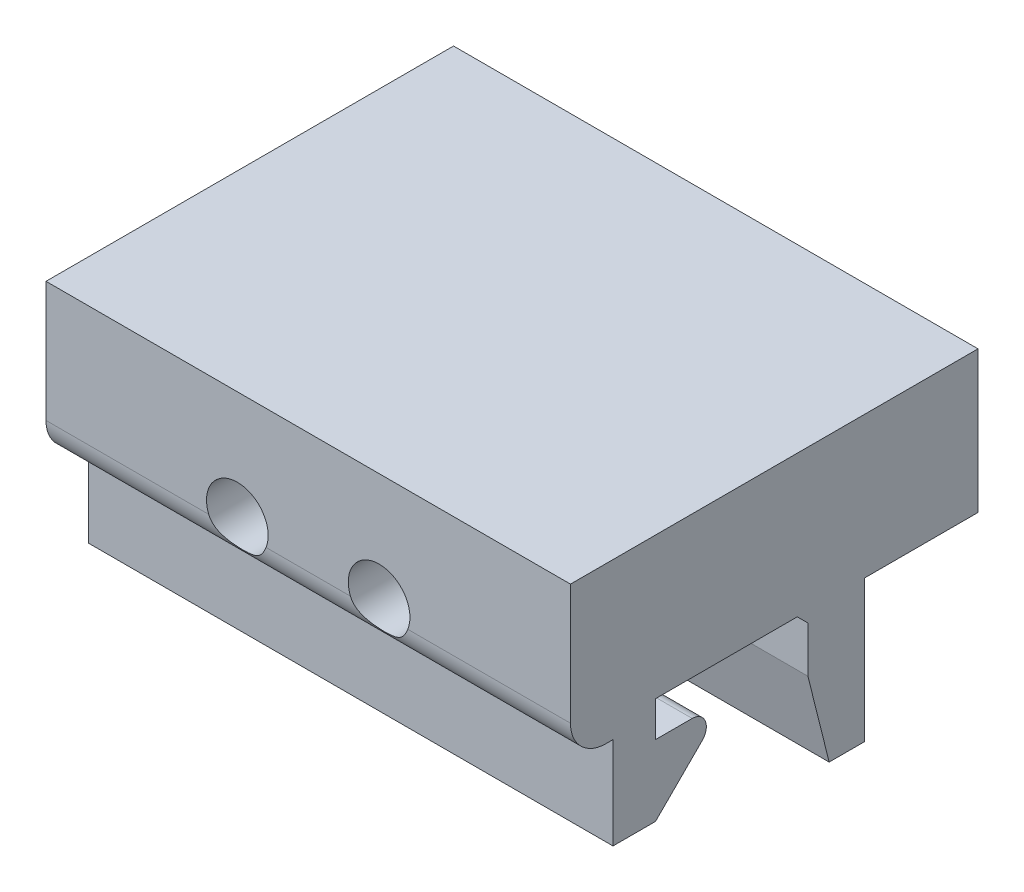
from build123d import *

# Parameters (mm, degrees)
BOSS_EXTRUDE1_DEPTH     = 37
SKETCH3_R               = 2.175
CUT_EXTRUDE1_DEPTH      = 9
CUT_EXTRUDE1_DEPTH_BACK = 21.75


with BuildPart() as part:
    # Sketch2 → Boss-Extrude1 (new body)
    with BuildSketch(Plane(origin=(0, 0, 0), x_dir=(0, 0, -1), z_dir=(1, 0, 0))):
        with BuildLine():
            Line((0, 0), (17.75, 0))
            Line((17.75, 0), (25.75, 0))
            Line((25.75, 0), (25.75, -10))
            Line((25.75, -10), (17.75, -10))
            Line((17.75, -10), (17.75, -20))
            Line((17.75, -20), (15.25, -20))
            Line((15.25, -20), (13.75, -14))
            Line((13.75, -14), (13.75, -10.75))
            Line((13.75, -10.75), (13, -10))
            Line((13, -10), (3, -10))
            Line((3, -10), (3, -12.5))
            Line((3, -12.5), (5.585786438, -12.5))
            ThreePointArc((5.585786438, -12.5), (6.50966597, -13.117316568), (6.292893219, -14.207106781))
            Line((6.292893219, -14.207106781), (3, -17.5))
            Line((3, -17.5), (0, -17.5))
            Line((0, -17.5), (0, -11))
            Line((0, -11), (-0.5, -11))
            ThreePointArc((-0.5, -11), (-2.267766953, -10.267766953), (-3, -8.5))
            Line((-3, -8.5), (-3, 0))
            Line((-3, 0), (0, 0))
        make_face()
    extrude(amount=BOSS_EXTRUDE1_DEPTH)

    # Sketch3 → Cut-Extrude1 (cut, two sides)
    with BuildSketch(Plane(origin=(0, 0, -17.75), x_dir=(-1, 0, 0), z_dir=(0, 0, -1))) as cut_extrude1_sk:
        with Locations((-23.5, -7.7)):
            Circle(SKETCH3_R)
        with Locations((-13.5, -7.7)):
            Circle(SKETCH3_R)
    extrude(amount=CUT_EXTRUDE1_DEPTH, mode=Mode.SUBTRACT)
    extrude(cut_extrude1_sk.sketch, amount=-CUT_EXTRUDE1_DEPTH_BACK, mode=Mode.SUBTRACT)


solid = part.part
